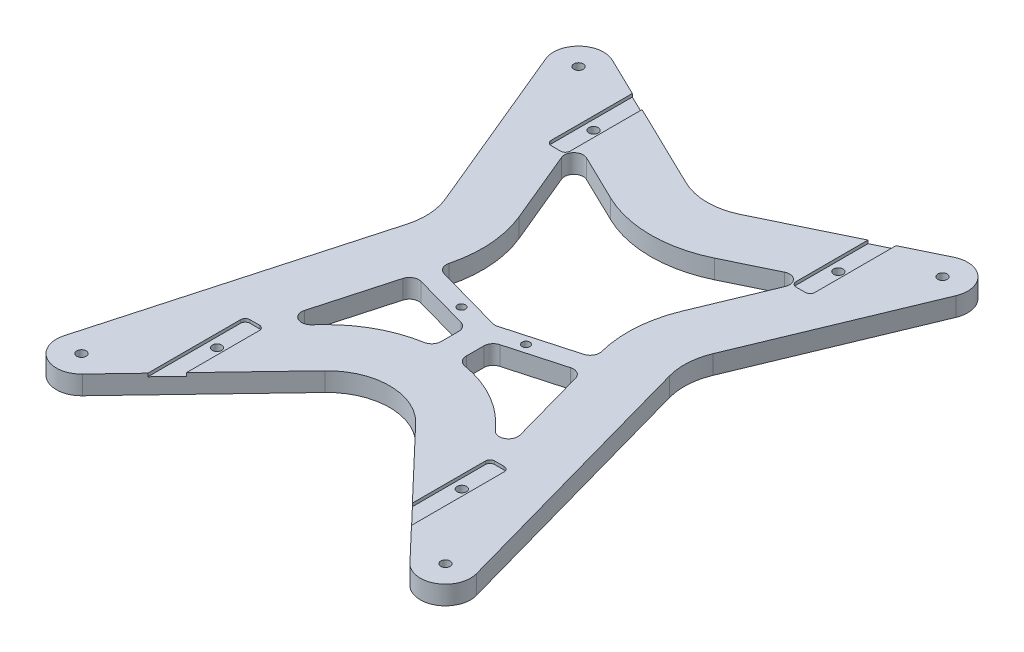
from build123d import *

# Parameters (mm, degrees)
SKETCH1_R           = 1.5
BOSS_EXTRUDE1_DEPTH = 6
FILLET1_R           = 20
CUT_EXTRUDE1_REACH  = 8
SKETCH5_R           = 1.25
BOSS_EXTRUDE2_DEPTH = 6
FILLET2_R           = 3
SKETCH6_W           = 6
SKETCH6_H           = 31.030846562
SKETCH6_H_2         = 27.343468982
CUT_EXTRUDE2_DEPTH  = 1
FILLET3_R           = 1.5


with BuildPart() as part:
    # Sketch1 → Boss-Extrude1 (new body)
    with BuildSketch(Plane(origin=(0, 0, 0), x_dir=(1, 0, 0), z_dir=(0, 1, 0))):
        with BuildLine():
            Line((-54.495367447, 86.395828983), (0, 60))
            Line((0, 60), (54.495367447, 86.395828983))
            ThreePointArc((54.495367447, 86.395828983), (63.474216903, 85.013506895), (65.371608634, 76.129225465))
            Line((65.371608634, 76.129225465), (40, 15))
            Line((40, 15), (65.688300647, -77.045475229))
            ThreePointArc((65.688300647, -77.045475229), (61.936793138, -86.150496915), (52.193978606, -84.717739607))
            Line((52.193978606, -84.717739607), (0, -30))
            Line((0, -30), (-52.193978606, -84.717739607))
            ThreePointArc((-52.193978606, -84.717739607), (-61.936793138, -86.150496915), (-65.688300647, -77.045475229))
            Line((-65.688300647, -77.045475229), (-40, 15))
            Line((-40, 15), (-65.371608634, 76.129225465))
            ThreePointArc((-65.371608634, 76.129225465), (-63.474216903, 85.013506895), (-54.495367447, 86.395828983))
        make_face()
        with Locations((-57.982756057, 79.195959493)):
            Circle(SKETCH1_R, mode=Mode.SUBTRACT)
        with Locations((57.982756057, 79.195959493)):
            Circle(SKETCH1_R, mode=Mode.SUBTRACT)
        with Locations((-57.982756057, -79.195959493)):
            Circle(SKETCH1_R, mode=Mode.SUBTRACT)
        with Locations((57.982756057, -79.195959493)):
            Circle(SKETCH1_R, mode=Mode.SUBTRACT)
        with Locations((-39, 65)):
            Circle(SKETCH1_R, mode=Mode.SUBTRACT)
        with Locations((39, 65)):
            Circle(SKETCH1_R, mode=Mode.SUBTRACT)
        with Locations((39, -55)):
            Circle(SKETCH1_R, mode=Mode.SUBTRACT)
        with Locations((-39, -55)):
            Circle(SKETCH1_R, mode=Mode.SUBTRACT)
    extrude(amount=BOSS_EXTRUDE1_DEPTH)

    # Fillet1
    fillet1_edges = [part.edges().sort_by_distance(p)[0] for p in [
        (0, 3, -60),
        (40, 3, -15),
        (0, 3, 30),
        (-40, 3, -15),
    ]]
    fillet(fillet1_edges, radius=FILLET1_R)

    # Sketch2 → Cut-Extrude1 (cut, up to next)
    with BuildSketch(Plane(origin=(0, 6, 0), x_dir=(1, 0, 0), z_dir=(0, 1, 0)), mode=Mode.PRIVATE) as cut_extrude1_sk1:
        with BuildLine():
            Line((-38.659149277, 58.724904233), (-26.025041931, 28.284847884))
            ThreePointArc((-26.025041931, 28.284847884), (-23.19190714, 16.020273346), (-24.520754868, 3.503060996))
            Line((-24.520754868, 3.503060996), (-37.591117294, -43.330232394))
            Line((-37.591117294, -43.330232394), (-27.496692892, -32.747707347))
            ThreePointArc((-27.496692892, -32.747707347), (0, -20.976162887), (27.496692892, -32.747707347))
            Line((27.496692892, -32.747707347), (37.591117294, -43.330232394))
            Line((37.591117294, -43.330232394), (24.520754868, 3.503060996))
            ThreePointArc((24.520754868, 3.503060996), (23.19190714, 16.020273346), (26.025041931, 28.284847884))
            Line((26.025041931, 28.284847884), (38.659149277, 58.724904233))
            Line((38.659149277, 58.724904233), (16.565095901, 48.023244958))
            ThreePointArc((16.565095901, 48.023244958), (0, 44.222625037), (-16.565095901, 48.023244958))
            Line((-16.565095901, 48.023244958), (-38.659149277, 58.724904233))
        make_face()
    cut_extrude1_tool1 = extrude(cut_extrude1_sk1.sketch, amount=-CUT_EXTRUDE1_REACH, mode=Mode.PRIVATE) & part.part
    add(cut_extrude1_tool1.solids().sort_by_distance((0, 6, -11.023996))[0], mode=Mode.SUBTRACT)

    # Sketch5 → Boss-Extrude2 (add)
    with BuildSketch(Plane(origin=(0, 6, 0), x_dir=(1, 0, 0), z_dir=(0, 1, 0))):
        with BuildLine():
            Line((-25.103227244, 1.415965109), (0, -5.589911573))
            Line((0, -5.589911573), (25.103227244, 1.415965109))
            Line((25.103227244, 1.415965109), (26.716090442, -4.363193333))
            Line((26.716090442, -4.363193333), (4, -10.702861409))
            Line((4, -10.702861409), (4, -21.187275631))
            ThreePointArc((4, -21.187275631), (0, -20.976162887), (-4, -21.187275631))
            Line((-4, -21.187275631), (-4, -10.702861409))
            Line((-4, -10.702861409), (-26.716090442, -4.363193333))
            Line((-26.716090442, -4.363193333), (-25.103227244, 1.415965109))
        make_face()
        with Locations((-10.3, -5.83)):
            Circle(SKETCH5_R, mode=Mode.SUBTRACT)
        with Locations((10.3, -5.83)):
            Circle(SKETCH5_R, mode=Mode.SUBTRACT)
    extrude(amount=-BOSS_EXTRUDE2_DEPTH)

    # Fillet2
    fillet2_edges = [part.edges().sort_by_distance(p)[0] for p in [
        (37.591117294, 3, 43.330232394),
        (-37.591117294, 3, 43.330232394),
        (38.659149277, 3, -58.724904233),
        (-38.659149277, 3, -58.724904233),
        (25.103227244, 3, -1.415965109),
        (-25.103227244, 3, -1.415965109),
        (0, 3, 5.589911573),
        (26.716090442, 3, 4.363193333),
        (4, 3, 10.702861409),
        (4, 3, 21.187275631),
        (-4, 3, 21.187275631),
        (-4, 3, 10.702861409),
        (-26.716090442, 3, 4.363193333),
    ]]
    fillet(fillet2_edges, radius=FILLET2_R)

    # Sketch6 → Cut-Extrude2 (cut)
    with BuildSketch(Plane(origin=(0, 6, 0), x_dir=(1, 0, 0), z_dir=(0, 1, 0))):
        with Locations((-39, -58.515423281)):
            Rectangle(SKETCH6_W, SKETCH6_H)
        with Locations((39, -58.515423281)):
            Rectangle(SKETCH6_W, SKETCH6_H)
        with Locations((39, 66.671734491)):
            Rectangle(SKETCH6_W, SKETCH6_H_2)
        with Locations((-39, 66.671734491)):
            Rectangle(SKETCH6_W, SKETCH6_H_2)
    extrude(amount=-CUT_EXTRUDE2_DEPTH, mode=Mode.SUBTRACT)

    # Fillet3
    fillet3_edges = [part.edges().sort_by_distance(p)[0] for p in [
        (-36, 5.5, 43),
        (-42, 5.5, 43),
        (36, 5.5, 43),
        (42, 5.5, 43),
        (36, 5.5, -53),
        (42, 5.5, -53),
        (-42, 5.5, -53),
        (-36, 5.5, -53),
    ]]
    fillet(fillet3_edges, radius=FILLET3_R)


solid = part.part
